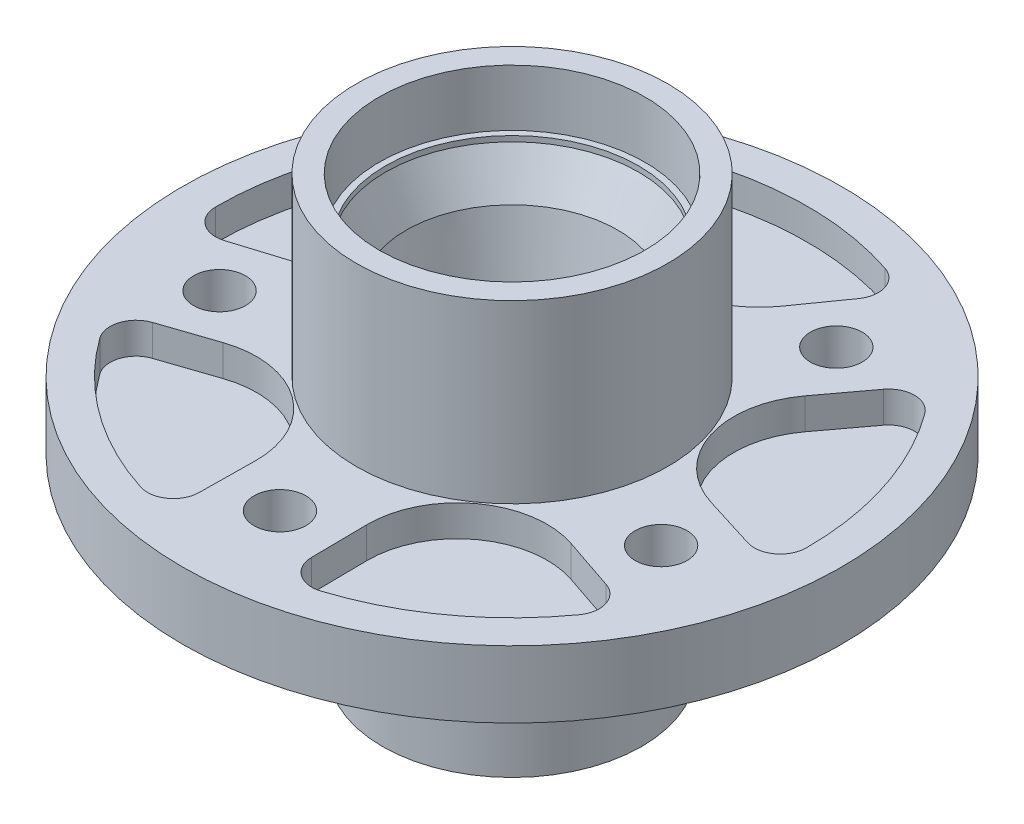
from build123d import *

# Parameters (mm, degrees)
SKETCH2_R          = 6.35
CUT_EXTRUDE1_DEPTH = 131.044155217
CIRPATTERN1_COUNT  = 5
CUT_EXTRUDE2_DEPTH = 7.62
CIRPATTERN2_COUNT  = 5


with BuildPart() as part:
    # Sketch1 → Revolve1 (revolve)
    with BuildSketch(Plane.XY):
        Polygon((32.512, 43.053), (38.1, 43.053), (38.1, 0), (80.645, 0), (80.645, -16.383), (31.75, -16.383), (31.75, -62.484), (25.4, -62.484), (25.4, -56.202878337), (20.567388856, -45.123813585), (22.706839799, -45.123813585), (22.706839799, -6.400010137), (26.858598141, 18.108781172), (25.922560718, 18.108781172), (30.977038212, 27.881202719), (30.977038212, 29.21), (32.512, 29.21), align=None)
    revolve(axis=Axis((0, 66.608222053, 0), (0, -1, 0)))

    # Sketch2 → Cut-Extrude1 (cut, through all)
    with BuildSketch(Plane(origin=(0, 0, 0), x_dir=(1, 0, 0), z_dir=(0, 1, 0))):
        with Locations((0, -56.798909535)):
            Circle(SKETCH2_R)
    cut_extrude1 = extrude(amount=-CUT_EXTRUDE1_DEPTH, mode=Mode.SUBTRACT)

    # CirPattern1: Cut-Extrude1 ×5 about axis
    cirpattern1_axis = Axis((0, 48.32985, 0), (0, -1, 0))
    for i in range(1, CIRPATTERN1_COUNT):
        add(cut_extrude1.rotate(cirpattern1_axis, i * 360 / CIRPATTERN1_COUNT), mode=Mode.SUBTRACT)

    # Sketch3 → Cut-Extrude2 (cut)
    with BuildSketch(Plane(origin=(0, 0, 0), x_dir=(1, 0, 0), z_dir=(0, 1, 0))):
        with BuildLine():
            Line((-25.816115671, 58.929202602), (-17.918089551, 47.780088903))
            ThreePointArc((-17.918089551, 47.780088903), (0, 38.514784655), (17.918089551, 47.780088903))
            Line((17.918089551, 47.780088903), (25.816115671, 58.929202602))
            ThreePointArc((25.816115671, 58.929202602), (26.666104709, 64.585415867), (22.622433381, 68.630654062))
            ThreePointArc((22.622433381, 68.630654062), (0, 72.263), (-22.622433381, 68.630654062))
            ThreePointArc((-22.622433381, 68.630654062), (-26.666104709, 64.585415867), (-25.816115671, 58.929202602))
        make_face()
    cut_extrude2 = extrude(amount=-CUT_EXTRUDE2_DEPTH, mode=Mode.SUBTRACT)

    # CirPattern2: Cut-Extrude2 ×5 about axis
    cirpattern2_axis = Axis((0, 48.32985, 0), (0, -1, 0))
    for i in range(1, CIRPATTERN2_COUNT):
        add(cut_extrude2.rotate(cirpattern2_axis, i * 360 / CIRPATTERN2_COUNT), mode=Mode.SUBTRACT)


solid = part.part
